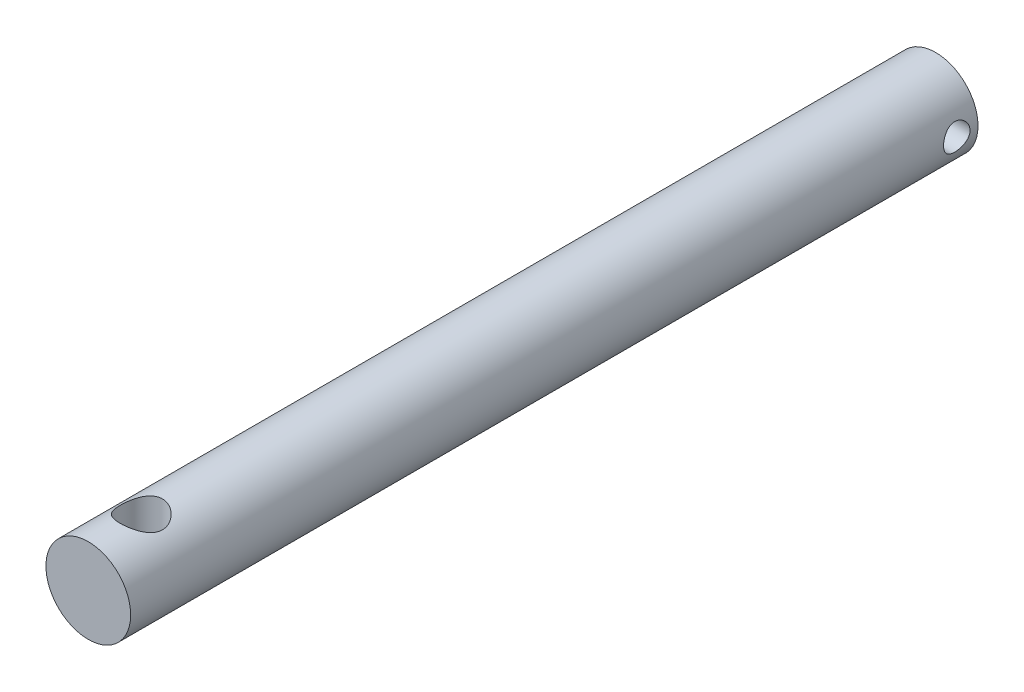
from build123d import *

# Parameters (mm, degrees)
SKETCH_1_R          = 8
EXTRUDE_1_DEPTH     = 160
SKETCH_2_R          = 4
CUT_EXTRUDE_1_DEPTH = 10
SKETCH_3_R          = 2.5
CUT_EXTRUDE_2_DEPTH = 10


with BuildPart() as part:
    # 草图1 → 凸台-拉伸1 (new body)
    with BuildSketch(Plane.XY):
        Circle(SKETCH_1_R)
    extrude(amount=EXTRUDE_1_DEPTH)

    # 草图2 → 切除-拉伸1 (cut, symmetric)
    with BuildSketch(Plane(origin=(0, 0, 0), x_dir=(1, 0, 0), z_dir=(0, 1, 0))):
        with Locations((0, -150)):
            Circle(SKETCH_2_R)
    extrude(amount=CUT_EXTRUDE_1_DEPTH, both=True, mode=Mode.SUBTRACT)

    # 草图3 → 切除-拉伸2 (cut)
    with BuildSketch(Plane(origin=(0, 0, 0), x_dir=(0, 0, -1), z_dir=(1, 0, 0))):
        with Locations((-4, 0)):
            Circle(SKETCH_3_R)
    extrude(amount=CUT_EXTRUDE_2_DEPTH, mode=Mode.SUBTRACT)


solid = part.part
